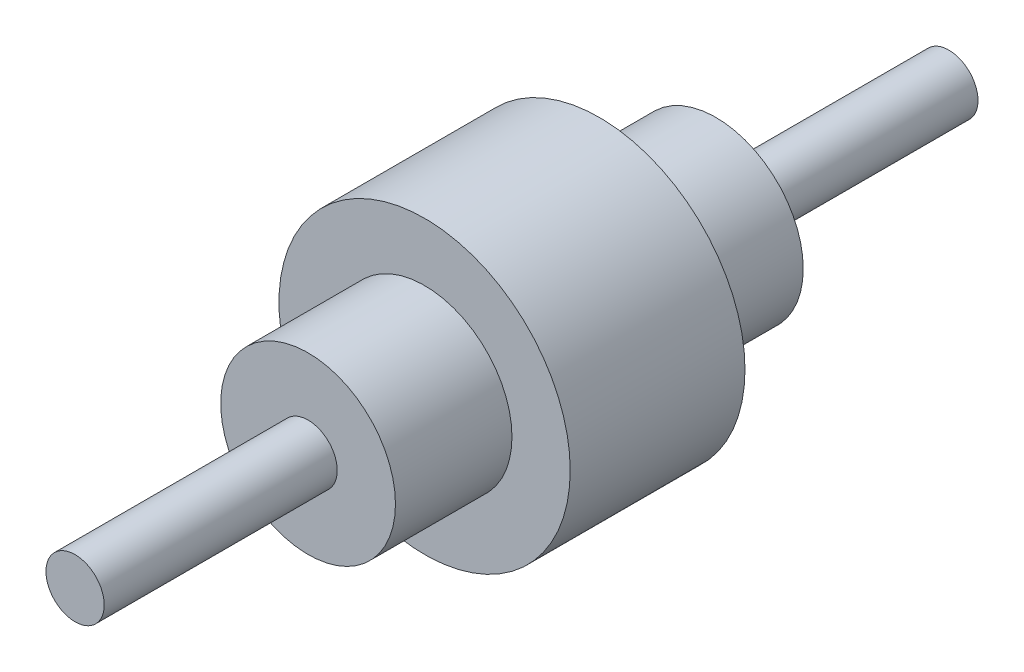
from build123d import *


with BuildPart() as part:
    # Sketch1 → Revolve1 (revolve)
    with BuildSketch(Plane(origin=(0, 0, 0), x_dir=(1, 0, 0), z_dir=(0, 1, 0))):
        Polygon((0, 300), (10, 300), (10, 220), (30, 220), (30, 180), (50, 180), (50, 120), (30, 120), (30, 80), (10, 80), (10, 0), (0, 0), align=None)
    revolve(axis=Axis((0, 0, 0), (0, 0, -1)))


solid = part.part
